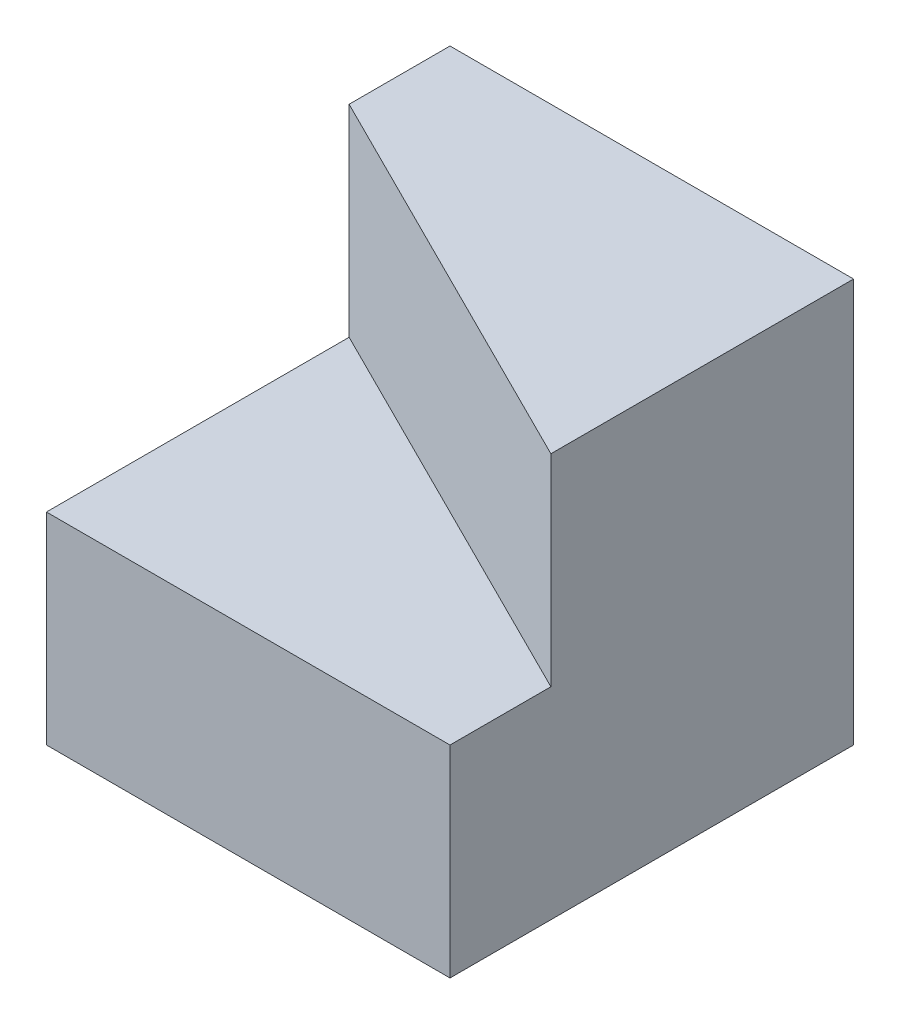
from build123d import *

# Parameters (mm, degrees)
SKETCH1_W           = 40
SKETCH1_H           = 40
BOSS_EXTRUDE1_DEPTH = 40
CUT_EXTRUDE1_DEPTH  = 20


with BuildPart() as part:
    # Sketch1 → Boss-Extrude1 (new body)
    with BuildSketch(Plane.XY):
        with Locations((20, 20)):
            Rectangle(SKETCH1_W, SKETCH1_H)
    extrude(amount=BOSS_EXTRUDE1_DEPTH)

    # Sketch3 → Cut-Extrude1 (cut)
    with BuildSketch(Plane(origin=(0, 40, 0), x_dir=(1, 0, 0), z_dir=(0, 1, 0))):
        Polygon((0, -10), (40, -30), (40, -40), (0, -40), align=None)
    extrude(amount=-CUT_EXTRUDE1_DEPTH, mode=Mode.SUBTRACT)


solid = part.part
